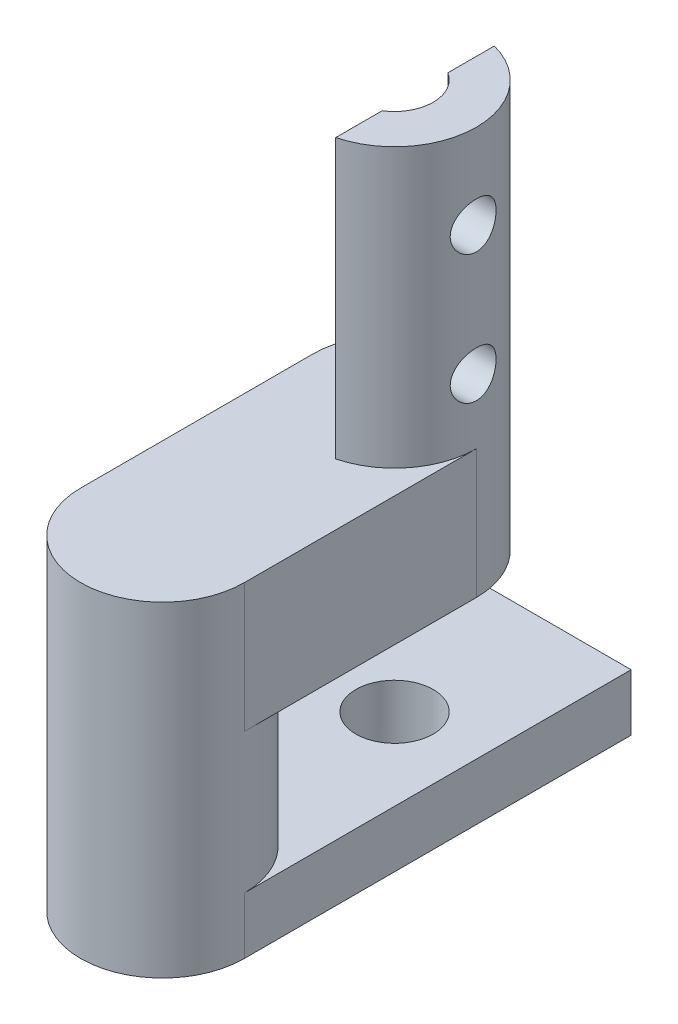
from build123d import *

# Parameters (mm, degrees)
SKETCH_1_R          = 3.175
EXTRUDE_1_DEPTH     = 57.15
CUT_EXTRUDE_1_DEPTH = 10.795
SKETCH_3_R          = 0.889
CUT_EXTRUDE_2_DEPTH = 10.795
SKETCH_4_R          = 3.175
CUT_EXTRUDE_3_DEPTH = 34.83
SKETCH_5_R          = 1.5
EXTRUDE_2_DEPTH     = 1.1
SKETCH_6_R          = 3.175
EXTRUDE_3_DEPTH     = 21.22
SKETCH_7_R          = 1.5
CUT_EXTRUDE_4_DEPTH = 28
SKETCH_8_W          = 3.969
SKETCH_8_H          = 6.35
CUT_EXTRUDE_5_DEPTH = 10.795
SKETCH_9_R          = 0.889
CUT_EXTRUDE_6_DEPTH = 10.795
EXTRUDE_4_DEPTH     = 5
SKETCH_11_R         = 3.175
CUT_EXTRUDE_7_DEPTH = 5.425
SKETCH_13_R         = 3.175
CUT_EXTRUDE_8_DEPTH = 10.795


with BuildPart() as part:
    # 草图1 → 凸台-拉伸1 (new body)
    with BuildSketch(Plane(origin=(0, 0, 0), x_dir=(1, 0, 0), z_dir=(0, 1, 0))):
        Circle(SKETCH_1_R)
    extrude(amount=EXTRUDE_1_DEPTH)

    # 草图2 → 切除-拉伸1 (cut)
    with BuildSketch(Plane(origin=(0, 57.15, 0), x_dir=(1, 0, 0), z_dir=(0, 1, 0))):
        Polygon((0.794, 3.175), (0.794, -3.175), (-3.175, -3.175), (-3.175, 3.175), (-3.175, 13.175), (0.794, 13.175), align=None)
    extrude(amount=-CUT_EXTRUDE_1_DEPTH, mode=Mode.SUBTRACT)

    # 草图3 → 切除-拉伸2 (cut)
    with BuildSketch(Plane.ZY.offset(-0.794)):
        with Locations((0, 53.855)):
            Circle(SKETCH_3_R)
        with Locations((0, 48.855)):
            Circle(SKETCH_3_R)
    extrude(amount=-CUT_EXTRUDE_2_DEPTH, mode=Mode.SUBTRACT)

    # 草图4 → 切除-拉伸3 (cut)
    with BuildSketch(Plane.XZ):
        Circle(SKETCH_4_R)
    extrude(amount=-CUT_EXTRUDE_3_DEPTH, mode=Mode.SUBTRACT)

    # 草图5 → 凸台-拉伸2 (add, symmetric)
    with BuildSketch(Plane.XZ.offset(-34.83)):
        with BuildLine():
            Line((3.175, 0), (3.175, -15))
            Line((3.175, -15), (-3.175, -15))
            Line((-3.175, -15), (-3.175, 0))
            ThreePointArc((-3.175, 0), (0, 3.175), (3.175, 0))
        make_face()
        with Locations((0, -9)):
            Circle(SKETCH_5_R, mode=Mode.SUBTRACT)
    extrude(amount=EXTRUDE_2_DEPTH, both=True)

    # 草图6 → 凸台-拉伸3 (add)
    with BuildSketch(Plane(origin=(0, 35.93, 0), x_dir=(1, 0, 0), z_dir=(0, 1, 0))):
        with Locations((0, 9)):
            Circle(SKETCH_6_R)
    extrude(amount=EXTRUDE_3_DEPTH)

    # 草图7 → 切除-拉伸4 (cut)
    with BuildSketch(Plane.XZ.offset(-33.73)):
        with Locations((0, -9)):
            Circle(SKETCH_7_R)
    extrude(amount=-CUT_EXTRUDE_4_DEPTH, mode=Mode.SUBTRACT)

    # 草图8 → 切除-拉伸5 (cut)
    with BuildSketch(Plane(origin=(0, 57.15, 0), x_dir=(1, 0, 0), z_dir=(0, 1, 0))):
        with Locations((-1.1905, 9)):
            Rectangle(SKETCH_8_W, SKETCH_8_H)
    extrude(amount=-CUT_EXTRUDE_5_DEPTH, mode=Mode.SUBTRACT)

    # 草图9 → 切除-拉伸6 (cut)
    with BuildSketch(Plane.ZY.offset(-0.794)):
        with Locations((-9, 48.855)):
            Circle(SKETCH_9_R)
        with Locations((-9, 53.855)):
            Circle(SKETCH_9_R)
    extrude(amount=-CUT_EXTRUDE_6_DEPTH, mode=Mode.SUBTRACT)

    # 草图10 → 凸台-拉伸4 (add)
    with BuildSketch(Plane(origin=(0, 46.355, 0), x_dir=(1, 0, 0), z_dir=(0, 1, 0))):
        with BuildLine():
            Line((-3.175, 0), (-3.175, 9))
            ThreePointArc((-3.175, 9), (0, 5.825), (3.175, 9))
            Line((3.175, 9), (3.175, 0))
            ThreePointArc((3.175, 0), (0, 3.175), (-3.175, 0))
        make_face()
    extrude(amount=-EXTRUDE_4_DEPTH)

    # 草图11 → 切除-拉伸7 (cut)
    with BuildSketch(Plane(origin=(0, 35.93, 0), x_dir=(1, 0, 0), z_dir=(0, 1, 0))):
        with Locations((0, 9)):
            Circle(SKETCH_11_R)
    extrude(amount=CUT_EXTRUDE_7_DEPTH, mode=Mode.SUBTRACT)

    # 草图13 → 切除-拉伸8 (cut)
    with BuildSketch(Plane(origin=(0, 46.355, 0), x_dir=(1, 0, 0), z_dir=(0, 1, 0))):
        Circle(SKETCH_13_R)
    extrude(amount=CUT_EXTRUDE_8_DEPTH, mode=Mode.SUBTRACT)


solid = part.part
